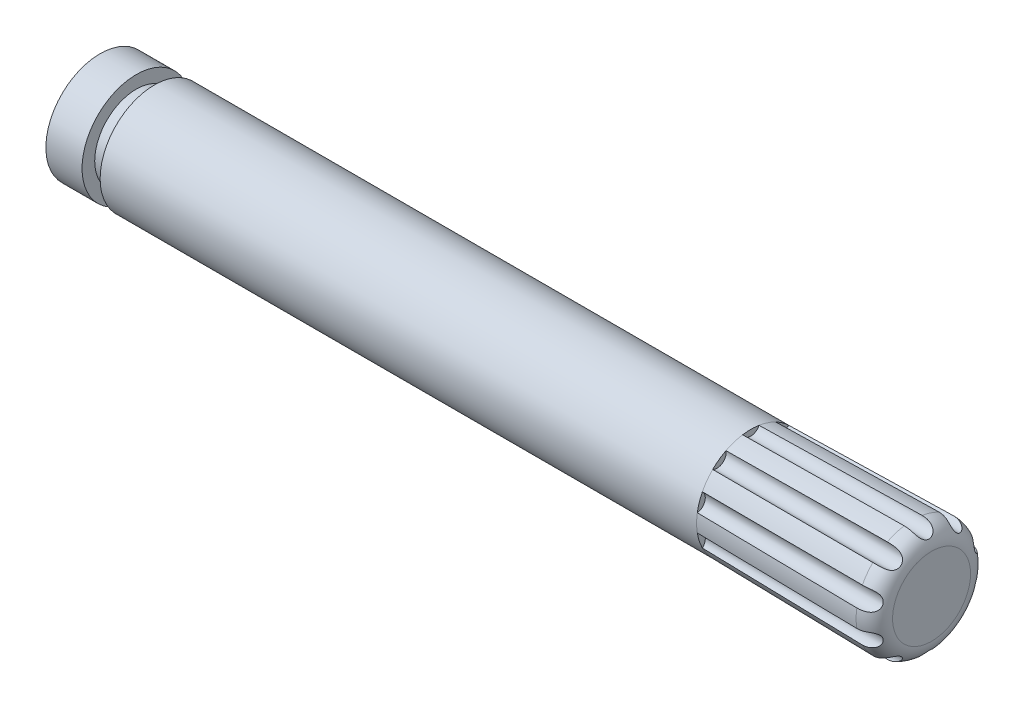
from build123d import *

# Parameters (mm, degrees)
SKETCH1_R                = 1.5
EXTRUDE1_DEPTH           = 18
EXTRUDE1_OTHER_WAY_DEPTH = 5
EXTRUDE1_OTHER_WAY_TAPER = -1
FILLET1_R                = 0.5
SKETCH2_R                = 0.25
CUT_EXTRUDE1_DEPTH       = 5
CIRPATTERN1_COUNT        = 10
SKETCH3_W                = 0.5
SKETCH3_H                = 0.930924855


with BuildPart() as part:
    # Sketch1 → Extrude1 (new body)
    with BuildSketch(Plane(origin=(0, 0, 0), x_dir=(0, 0, -1), z_dir=(1, 0, 0))):
        Circle(SKETCH1_R)
    extrude(amount=-EXTRUDE1_DEPTH)

    # Sketch1 → Extrude1 other way (add)
    with BuildSketch(Plane(origin=(0, 0, 0), x_dir=(0, 0, -1), z_dir=(1, 0, 0))):
        Circle(SKETCH1_R)
    extrude(amount=EXTRUDE1_OTHER_WAY_DEPTH, taper=EXTRUDE1_OTHER_WAY_TAPER)

    # Fillet1
    fillet1_edges = [part.edges().sort_by_distance(p)[0] for p in [
        (5, 0, 1.587275325),
    ]]
    fillet(fillet1_edges, radius=FILLET1_R)

    # Sketch2 → Cut-Extrude1 (cut)
    with BuildSketch(Plane(origin=(5, 0, 0), x_dir=(0, 0, -1), z_dir=(1, 0, 0))):
        with Locations((0, 1.587275325)):
            Circle(SKETCH2_R)
    cut_extrude1 = extrude(amount=-CUT_EXTRUDE1_DEPTH, mode=Mode.SUBTRACT)

    # CirPattern1: Cut-Extrude1 ×10 about axis
    cirpattern1_axis = Axis((0, 0, 0), (1, 0, 0))
    for i in range(1, CIRPATTERN1_COUNT):
        add(cut_extrude1.rotate(cirpattern1_axis, i * 360 / CIRPATTERN1_COUNT), mode=Mode.SUBTRACT)

    # Sketch3 → Cut-Revolve2 (revolve, cut)
    with BuildSketch(Plane.XY):
        with Locations((-16.75, 1.615462428)):
            Rectangle(SKETCH3_W, SKETCH3_H)
    revolve(axis=Axis((-18, 0, 0), (1, 0, 0)), mode=Mode.SUBTRACT)


solid = part.part
